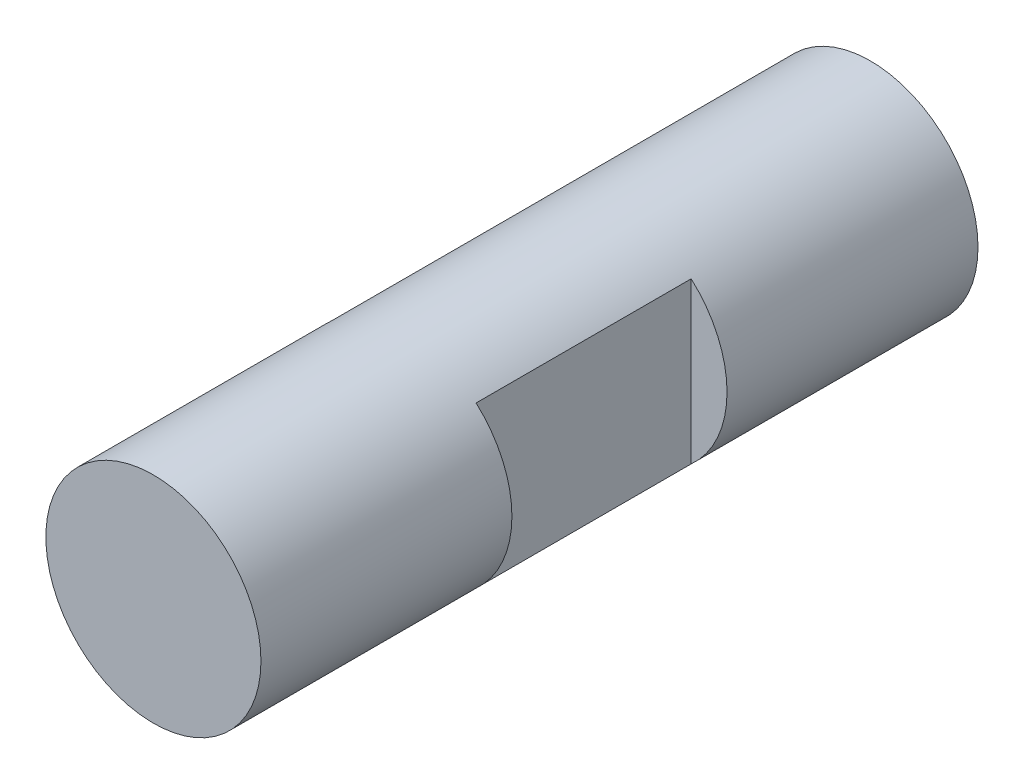
from build123d import *

# Parameters (mm, degrees)
SKETCH_1_R          = 6
EXTRUDE_1_DEPTH     = 40
SKETCH_3_W          = 12
SKETCH_3_H          = 9
CUT_EXTRUDE_1_DEPTH = 40
DRAFT_3_ANGLE       = 30


with BuildPart() as part:
    # 草图1 → 凸台-拉伸1 (new body)
    with BuildSketch(Plane.XY):
        Circle(SKETCH_1_R)
    extrude(amount=EXTRUDE_1_DEPTH)

    # 草图3 → 切除-拉伸1 (cut)
    with BuildSketch(Plane(origin=(4, 0, 0), x_dir=(0, 0, -1), z_dir=(1, 0, 0))):
        with Locations((-20, 0)):
            Rectangle(SKETCH_3_W, SKETCH_3_H)
    cut_extrude_1 = extrude(amount=CUT_EXTRUDE_1_DEPTH, mode=Mode.SUBTRACT)

    # 镜向1: 切除-拉伸1 across plane
    add(cut_extrude_1.mirror(Plane(origin=(0, 0, 0), x_dir=(0, 0, 1), z_dir=(1, 0, 0))), mode=Mode.SUBTRACT)

    # 拔模3
    draft_3_faces = [part.faces().sort_by_distance(p)[0] for p in [
        (-4.812657334, 0, 26),
    ]]
    draft(draft_3_faces, Plane(origin=(-4, 0, 0), x_dir=(0, 0, -1), z_dir=(-1, 0, 0)), DRAFT_3_ANGLE)


solid = part.part
